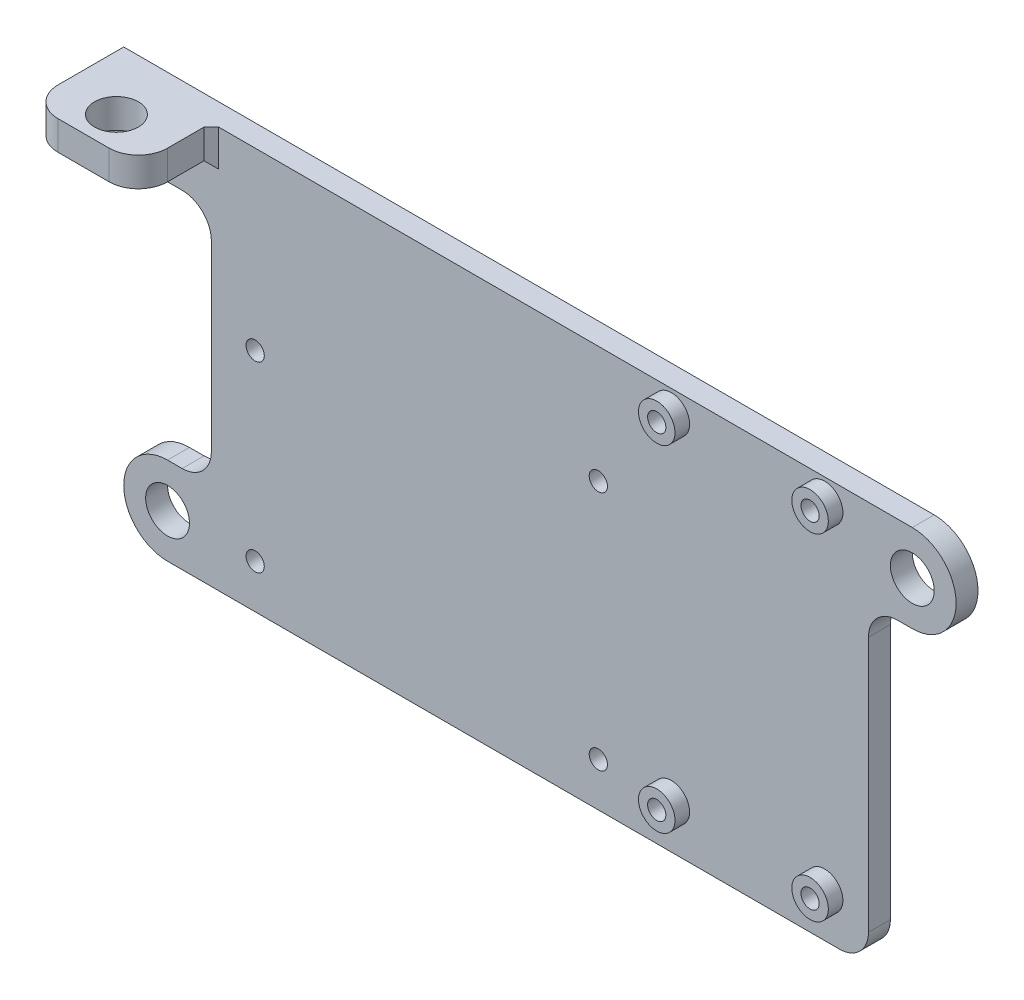
from build123d import *

# Parameters (mm, degrees)
SKETCH_1_W      = 90
SKETCH_1_H      = 55
SKETCH_1_R      = 1.25
EXTRUDE_1_DEPTH = 3
SKETCH_2_R      = 3
EXTRUDE_2_DEPTH = 3
SKETCH_3_W      = 15
SKETCH_3_H      = 10
SKETCH_3_R      = 3
EXTRUDE_3_DEPTH = 4
CHAMFER_1_SIZE  = 1
SKETCH_4_R      = 2.5
SKETCH_4_R_2    = 1.25
EXTRUDE_4_DEPTH = 2
FILLET_1_R      = 4


with BuildPart() as part:
    # Эскиз1 → Бобышка-Вытянуть1 (new body)
    with BuildSketch(Plane.XY):
        with Locations((45, 27.5)):
            Rectangle(SKETCH_1_W, SKETCH_1_H)
        with Locations((6, 31)):
            Circle(SKETCH_1_R, mode=Mode.SUBTRACT)
        with Locations((6, 6)):
            Circle(SKETCH_1_R, mode=Mode.SUBTRACT)
        with Locations((53, 39)):
            Circle(SKETCH_1_R, mode=Mode.SUBTRACT)
        with Locations((53, 6)):
            Circle(SKETCH_1_R, mode=Mode.SUBTRACT)
        with Locations((63, 6)):
            Circle(SKETCH_1_R, mode=Mode.SUBTRACT)
        with Locations((63, 52)):
            Circle(SKETCH_1_R, mode=Mode.SUBTRACT)
        with Locations((84, 52)):
            Circle(SKETCH_1_R, mode=Mode.SUBTRACT)
        with Locations((84, 6)):
            Circle(SKETCH_1_R, mode=Mode.SUBTRACT)
    extrude(amount=EXTRUDE_1_DEPTH)

    # Эскиз2 → Бобышка-Вытянуть2 (add)
    with BuildSketch(Plane.XY.offset(3)):
        with BuildLine():
            Line((0, 55), (-15, 55))
            Line((-15, 55), (-15, 45))
            Line((-15, 45), (-4, 45))
            ThreePointArc((-4, 45), (-1.171572875, 43.828427125), (0, 41))
            Line((0, 41), (0, 55))
        make_face()
        with BuildLine():
            Line((0, 0), (-6, 0))
            ThreePointArc((-6, 0), (-12, 6), (-6, 12))
            Line((-6, 12), (-4, 12))
            ThreePointArc((-4, 12), (-1.171572875, 13.171572875), (0, 16))
            Line((0, 16), (0, 0))
        make_face()
        with Locations((-6, 6)):
            Circle(SKETCH_2_R, mode=Mode.SUBTRACT)
        with BuildLine():
            Line((90, 55), (96, 55))
            ThreePointArc((96, 55), (102, 49), (96, 43))
            Line((96, 43), (94, 43))
            ThreePointArc((94, 43), (91.171572875, 41.828427125), (90, 39))
            Line((90, 39), (90, 55))
        make_face()
        with Locations((96, 49)):
            Circle(SKETCH_2_R, mode=Mode.SUBTRACT)
    extrude(amount=-EXTRUDE_2_DEPTH)

    # Эскиз3 → Бобышка-Вытянуть3 (add)
    with BuildSketch(Plane(origin=(0, 55, 0), x_dir=(1, 0, 0), z_dir=(0, 1, 0))):
        with Locations((-7.5, -8)):
            Rectangle(SKETCH_3_W, SKETCH_3_H)
        with Locations((-7.5, -8.5)):
            Circle(SKETCH_3_R, mode=Mode.SUBTRACT)
    extrude(amount=-EXTRUDE_3_DEPTH)

    # Фаска1
    chamfer_1_edges = [part.edges().sort_by_distance(p)[0] for p in [
        (-7.5, 51, 3),
        (0, 53, 3),
    ]]
    chamfer(chamfer_1_edges, length=CHAMFER_1_SIZE)

    # Эскиз4 → Бобышка-Вытянуть4 (add)
    with BuildSketch(Plane.XY.offset(3)):
        with Locations((63, 52)):
            Circle(SKETCH_4_R)
        with Locations((63, 52)):
            Circle(SKETCH_4_R_2, mode=Mode.SUBTRACT)
        with Locations((84, 52)):
            Circle(SKETCH_4_R)
        with Locations((84, 52)):
            Circle(SKETCH_4_R_2, mode=Mode.SUBTRACT)
        with Locations((63, 6)):
            Circle(SKETCH_4_R)
        with Locations((63, 6)):
            Circle(SKETCH_4_R_2, mode=Mode.SUBTRACT)
        with Locations((84, 6)):
            Circle(SKETCH_4_R)
        with Locations((84, 6)):
            Circle(SKETCH_4_R_2, mode=Mode.SUBTRACT)
    extrude(amount=EXTRUDE_4_DEPTH)

    # Скругление1
    fillet_1_edges = [part.edges().sort_by_distance(p)[0] for p in [
        (-15, 45, 1.5),
        (90, 0, 1.5),
        (-15, 53, 13),
        (0, 53, 13),
    ]]
    fillet(fillet_1_edges, radius=FILLET_1_R)


solid = part.part
